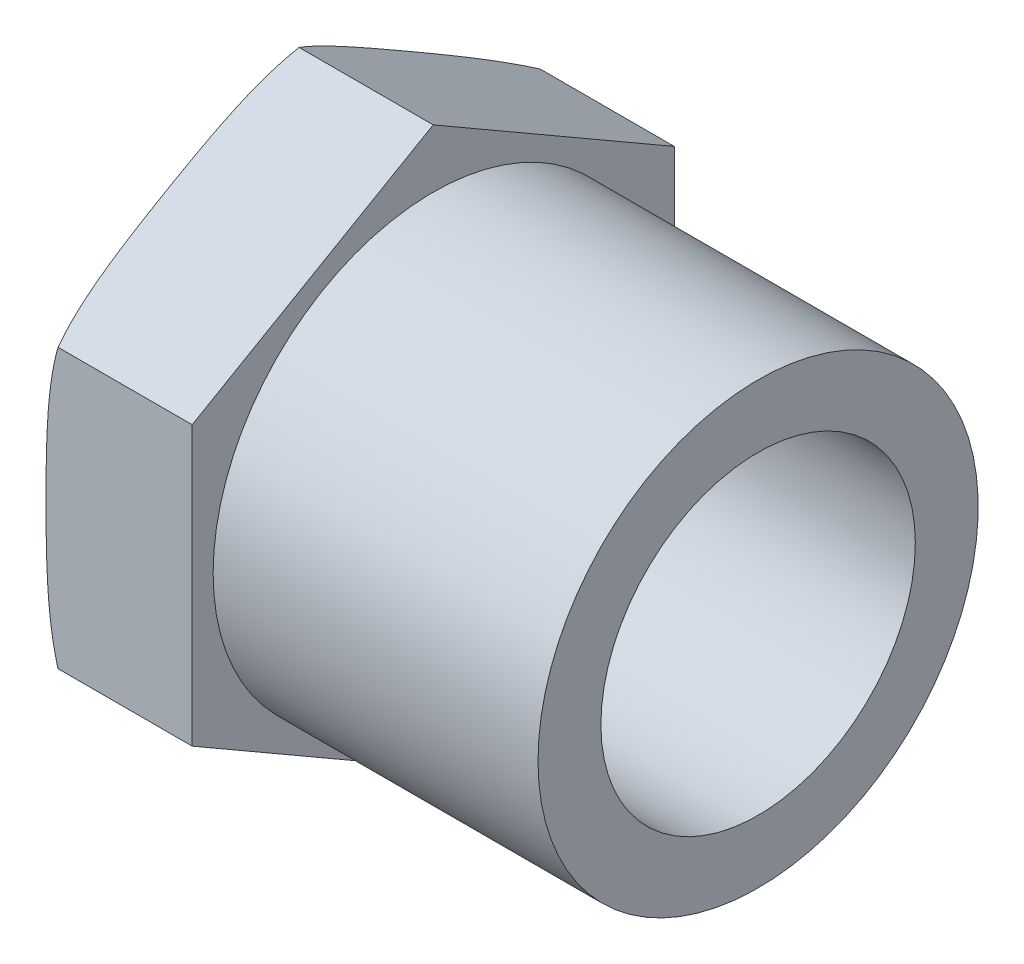
from build123d import *

# Parameters (mm, degrees)
SKETCH2_R           = 6.5
BOSS_EXTRUDE1_DEPTH = 7


with BuildPart() as part:
    # Sketch1 → Revolve1 (revolve)
    with BuildSketch(Plane.XY):
        with BuildLine():
            Line((0, 6.5), (0, 10.5))
            Line((0, 10.5), (22.5, 10.5))
            Line((22.5, 10.5), (22.5, 7.5))
            Line((22.5, 7.5), (10.5, 7.5))
            ThreePointArc((10.5, 7.5), (10.146446609, 7.353553391), (10, 7))
            Line((10, 7), (10, 6.5))
            Line((10, 6.5), (0, 6.5))
        make_face()
    revolve(axis=Axis((0, 0, 0), (1, 0, 0)))

    # Sketch2 → Boss-Extrude1 (add)
    with BuildSketch(Plane.ZY):
        Polygon((0, 13.279056191), (-11.5, 6.639528096), (-11.5, -6.639528096), (0, -13.279056191), (11.5, -6.639528096), (11.5, 6.639528096), align=None)
        Circle(SKETCH2_R, mode=Mode.SUBTRACT)
    extrude(amount=-BOSS_EXTRUDE1_DEPTH)

    # Cut-Sweep1: sweep along a path in Sketch6
    with BuildLine(Plane.ZY) as cut_sweep1_path:
        CenterArc((0, 0), 11.5, 0, 360)
    # Sketch5 → Cut-Sweep1 (sweep, cut)
    with BuildSketch(Plane.XY):
        with BuildLine():
            Line((0.6, 13.279056191), (0, 13.279056191))
            Line((0, 13.279056191), (0, 11))
            ThreePointArc((0, 11), (0.152512755, 12.178356602), (0.6, 13.279056191))
        make_face()
    sweep(path=cut_sweep1_path.line, mode=Mode.SUBTRACT)


solid = part.part
